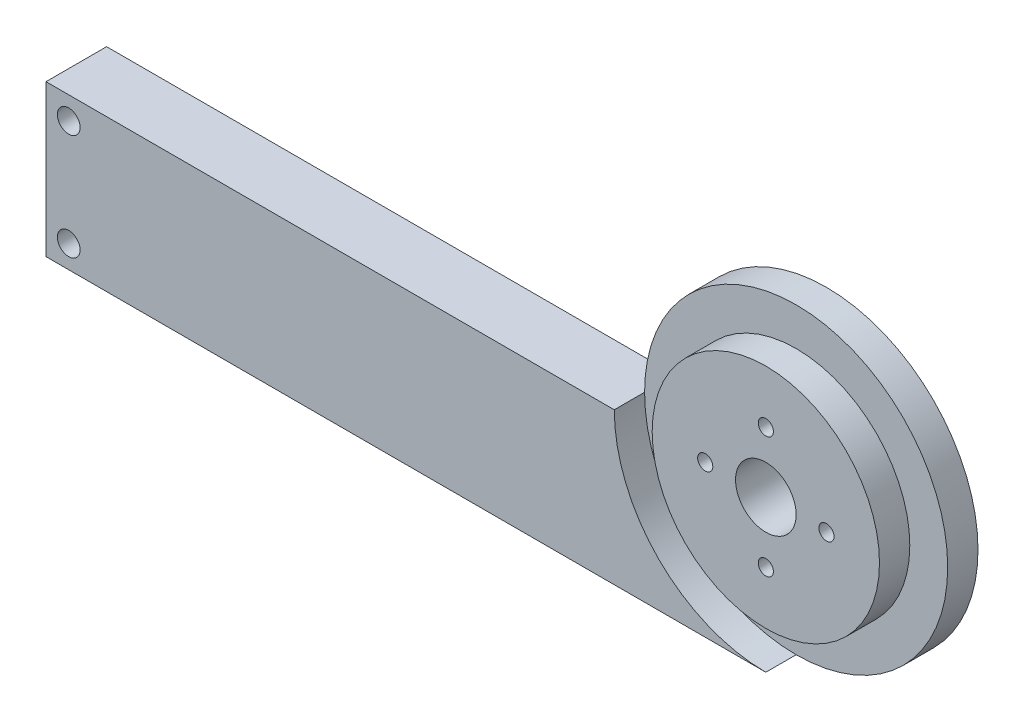
from build123d import *

# Parameters (mm, degrees)
BOSS_EXTRU_1_DEPTH      = 8
ESQUISSE4_R             = 20
ESQUISSE4_R_2           = 15
ENL_V_MAT_EXTRU_2_DEPTH = 4
ESQUISSE5_W             = 16.42
ESQUISSE5_H             = 20
BOSS_EXTRU_2_DEPTH      = 8
ESQUISSE6_R             = 4
ESQUISSE6_R_2           = 1
ENL_V_MAT_EXTRU_3_DEPTH = 10
ESQUISSE7_R             = 1.5
ENL_V_MAT_EXTRU_4_DEPTH = 10


with BuildPart() as part:
    # Esquisse1 → Boss.-Extru.1 (new body)
    with BuildSketch(Plane.XY):
        with BuildLine():
            ThreePointArc((52.992232765, 28.099272116), (32.992232765, 48.099272116), (12.992232765, 28.099272116))
            Line((12.992232765, 28.099272116), (32.992232765, 28.099272116))
            Line((32.992232765, 28.099272116), (32.992232765, 8.099272116))
            ThreePointArc((32.992232765, 8.099272116), (47.134368389, 13.957136493), (52.992232765, 28.099272116))
        make_face()
        with BuildLine():
            Line((32.992232765, 28.099272116), (12.992232765, 28.099272116))
            ThreePointArc((12.992232765, 28.099272116), (18.850097141, 13.957136493), (32.992232765, 8.099272116))
            Line((32.992232765, 8.099272116), (32.992232765, 28.099272116))
        make_face()
        with BuildLine():
            Line((12.992232765, 28.099272116), (-45.58279523, 28.099272116))
            Line((-45.58279523, 28.099272116), (-45.58279523, 8.099272116))
            Line((-45.58279523, 8.099272116), (32.992232765, 8.099272116))
            ThreePointArc((32.992232765, 8.099272116), (18.850097141, 13.957136493), (12.992232765, 28.099272116))
        make_face()
    extrude(amount=BOSS_EXTRU_1_DEPTH)

    # Esquisse4 → Enlèv. mat.-Extru.2 (cut)
    with BuildSketch(Plane.XY.offset(8)):
        with Locations((32.992232765, 28.099272116)):
            Circle(ESQUISSE4_R)
        with Locations((32.992232765, 28.099272116)):
            Circle(ESQUISSE4_R_2, mode=Mode.SUBTRACT)
    extrude(amount=-ENL_V_MAT_EXTRU_2_DEPTH, mode=Mode.SUBTRACT)

    # Esquisse5 → Boss.-Extru.2 (add)
    with BuildSketch(Plane.XY.offset(8)):
        with Locations((-53.79279523, 18.099272116)):
            Rectangle(ESQUISSE5_W, ESQUISSE5_H)
    extrude(amount=-BOSS_EXTRU_2_DEPTH)

    # Esquisse6 → Enlèv. mat.-Extru.3 (cut)
    with BuildSketch(Plane.XY.offset(8)):
        with Locations((32.992232765, 28.099272116)):
            Circle(ESQUISSE6_R)
        with Locations((32.992232765, 36.099272116)):
            Circle(ESQUISSE6_R_2)
        with Locations((40.992232765, 28.099272116)):
            Circle(ESQUISSE6_R_2)
        with Locations((32.992232765, 20.099272116)):
            Circle(ESQUISSE6_R_2)
        with Locations((24.992232765, 28.099272116)):
            Circle(ESQUISSE6_R_2)
    extrude(amount=-ENL_V_MAT_EXTRU_3_DEPTH, mode=Mode.SUBTRACT)

    # Esquisse7 → Enlèv. mat.-Extru.4 (cut)
    with BuildSketch(Plane.XY.offset(8)):
        with Locations((-59.00279523, 25.099272116)):
            Circle(ESQUISSE7_R)
        with Locations((-59.00279523, 11.099272116)):
            Circle(ESQUISSE7_R)
    extrude(amount=-ENL_V_MAT_EXTRU_4_DEPTH, mode=Mode.SUBTRACT)


solid = part.part
